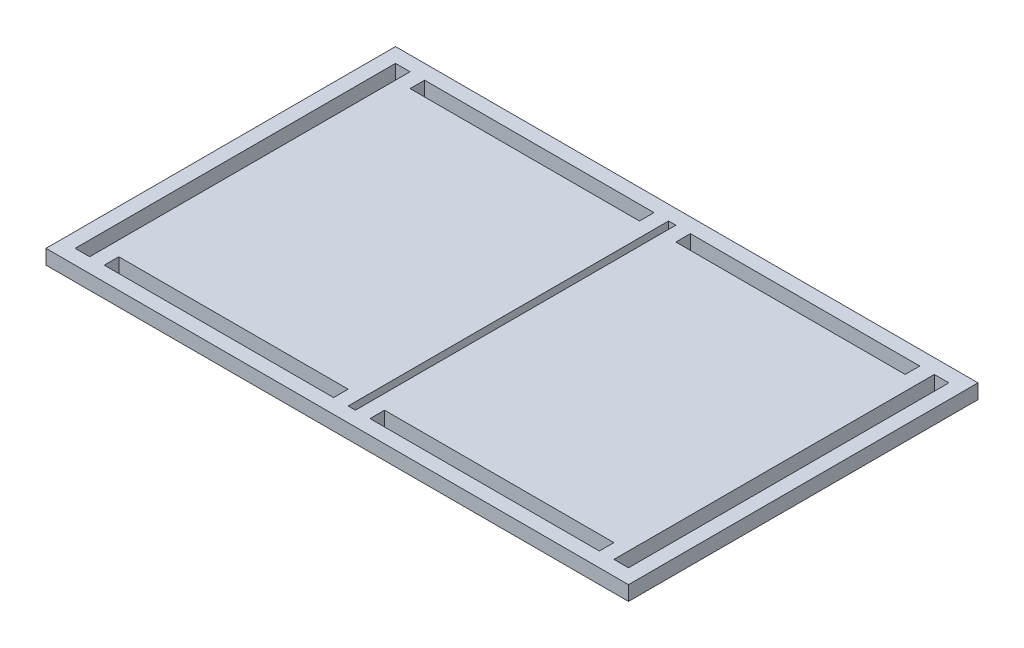
from build123d import *

# Parameters (mm, degrees)
SKETCH1_W           = 254
SKETCH1_H           = 152.4
SKETCH1_W_2         = 6.35
SKETCH1_H_2         = 139.7
SKETCH1_W_3         = 3.175
SKETCH1_W_4         = 100.0125
SKETCH1_H_3         = 6.34492
BOSS_EXTRUDE1_DEPTH = 6.35


with BuildPart() as part:
    # Sketch1 → Boss-Extrude1 (new body)
    with BuildSketch(Plane(origin=(0, 0, 0), x_dir=(1, 0, 0), z_dir=(0, 1, 0))):
        Rectangle(SKETCH1_W, SKETCH1_H)
        with Locations((117.475, 0)):
            Rectangle(SKETCH1_W_2, SKETCH1_H_2, mode=Mode.SUBTRACT)
        Rectangle(SKETCH1_W_3, SKETCH1_H_2, mode=Mode.SUBTRACT)
        with Locations((-117.475, 0)):
            Rectangle(SKETCH1_W_2, SKETCH1_H_2, mode=Mode.SUBTRACT)
        with Locations((-57.94375, 66.67754)):
            Rectangle(SKETCH1_W_4, SKETCH1_H_3, mode=Mode.SUBTRACT)
        with Locations((57.94375, -66.68262)):
            Rectangle(SKETCH1_W_4, SKETCH1_H_3, mode=Mode.SUBTRACT)
        with Locations((57.94375, 66.67754)):
            Rectangle(SKETCH1_W_4, SKETCH1_H_3, mode=Mode.SUBTRACT)
        with Locations((-57.94375, -66.67754)):
            Rectangle(SKETCH1_W_4, SKETCH1_H_3, mode=Mode.SUBTRACT)
    extrude(amount=BOSS_EXTRUDE1_DEPTH)


solid = part.part
